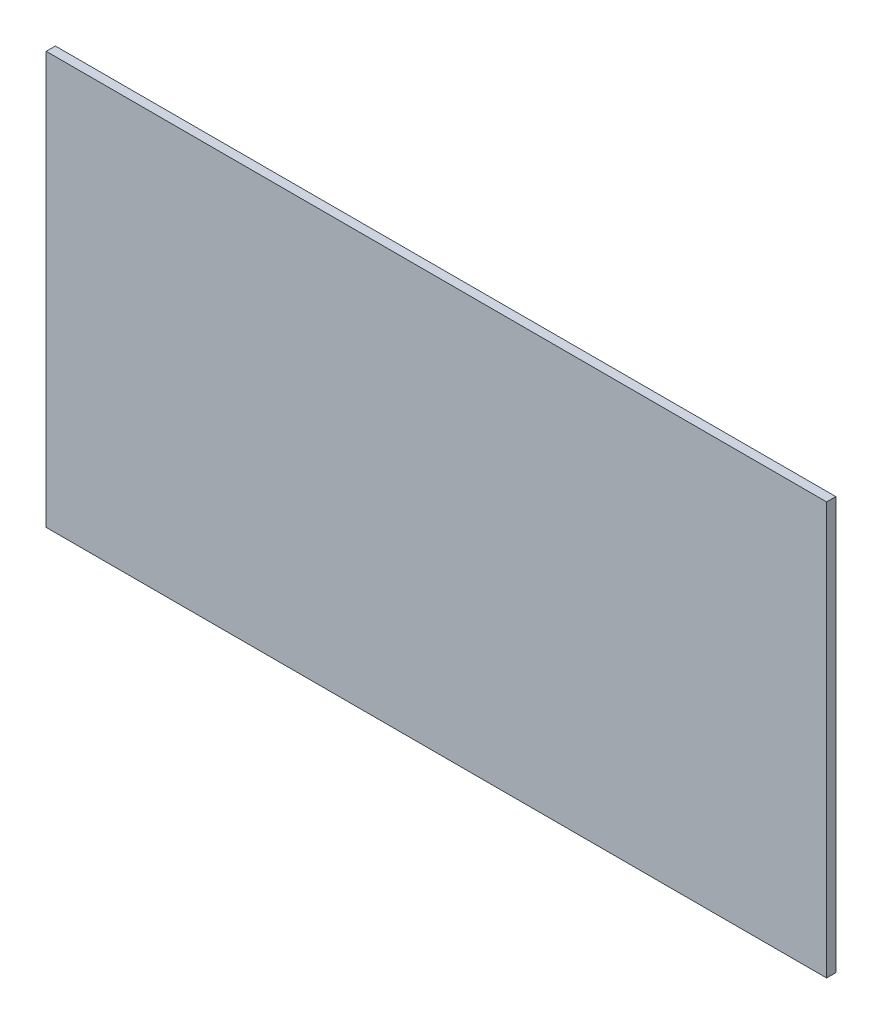
from build123d import *

# Parameters (mm, degrees)
SKETCH1_W           = 1700
SKETCH1_H           = 898.157210254
BOSS_EXTRUDE1_DEPTH = 20


with BuildPart() as part:
    # Sketch1 → Boss-Extrude1 (new body)
    with BuildSketch(Plane.XY):
        with Locations((850, 449.078605127)):
            Rectangle(SKETCH1_W, SKETCH1_H)
    extrude(amount=BOSS_EXTRUDE1_DEPTH)


solid = part.part
